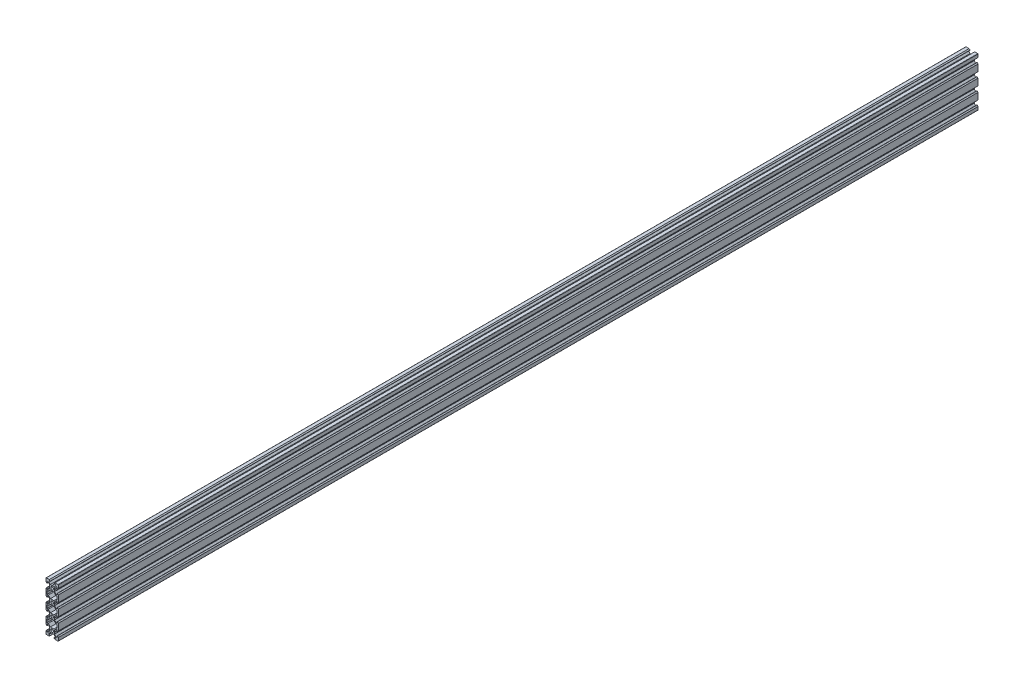
from build123d import *

# Parameters (mm, degrees)
SKETCH1_R           = 2.1
BOSS_EXTRUDE1_DEPTH = 1500


with BuildPart() as part:
    # Sketch1 → Boss-Extrude1 (new body)
    with BuildSketch(Plane.XY):
        with BuildLine():
            Line((4.58, -40), (9.5, -40))
            ThreePointArc((9.5, -40), (9.853553391, -39.853553391), (10, -39.5))
            Line((10, -39.5), (10, -34.58))
            Line((10, -34.58), (8.545, -33.125))
            Line((8.545, -33.125), (8.2, -33.125))
            Line((8.2, -33.125), (8.2, -35.5))
            Line((8.2, -35.5), (6.560660172, -35.5))
            Line((6.560660172, -35.5), (3.9, -32.839339828))
            Line((3.9, -32.839339828), (3.9, -30.21))
            Line((3.9, -30.21), (3.69, -30))
            Line((3.69, -30), (3.9, -29.79))
            Line((3.9, -29.79), (3.9, -27.160660172))
            Line((3.9, -27.160660172), (6.560660172, -24.5))
            Line((6.560660172, -24.5), (8.2, -24.5))
            Line((8.2, -24.5), (8.2, -26.875))
            Line((8.2, -26.875), (8.545, -26.875))
            Line((8.545, -26.875), (10, -25.42))
            Line((10, -25.42), (10, -14.58))
            Line((10, -14.58), (8.545, -13.125))
            Line((8.545, -13.125), (8.2, -13.125))
            Line((8.2, -13.125), (8.2, -15.5))
            Line((8.2, -15.5), (6.560660172, -15.5))
            Line((6.560660172, -15.5), (3.9, -12.839339828))
            Line((3.9, -12.839339828), (3.9, -10.21))
            Line((3.9, -10.21), (3.69, -10))
            Line((3.69, -10), (3.9, -9.79))
            Line((3.9, -9.79), (3.9, -7.160660172))
            Line((3.9, -7.160660172), (6.560660172, -4.5))
            Line((6.560660172, -4.5), (8.2, -4.5))
            Line((8.2, -4.5), (8.2, -6.875))
            Line((8.2, -6.875), (8.545, -6.875))
            Line((8.545, -6.875), (10, -5.42))
            Line((10, -5.42), (10, 5.42))
            Line((10, 5.42), (8.545, 6.875))
            Line((8.545, 6.875), (8.2, 6.875))
            Line((8.2, 6.875), (8.2, 4.5))
            Line((8.2, 4.5), (6.560660172, 4.5))
            Line((6.560660172, 4.5), (3.9, 7.160660172))
            Line((3.9, 7.160660172), (3.9, 9.79))
            Line((3.9, 9.79), (3.69, 10))
            Line((3.69, 10), (3.9, 10.21))
            Line((3.9, 10.21), (3.9, 12.839339828))
            Line((3.9, 12.839339828), (6.560660172, 15.5))
            Line((6.560660172, 15.5), (8.2, 15.5))
            Line((8.2, 15.5), (8.2, 13.125))
            Line((8.2, 13.125), (8.545, 13.125))
            Line((8.545, 13.125), (10, 14.58))
            Line((10, 14.58), (10, 25.42))
            Line((10, 25.42), (8.545, 26.875))
            Line((8.545, 26.875), (8.2, 26.875))
            Line((8.2, 26.875), (8.2, 24.5))
            Line((8.2, 24.5), (6.560660172, 24.5))
            Line((6.560660172, 24.5), (3.9, 27.160660172))
            Line((3.9, 27.160660172), (3.9, 29.79))
            Line((3.9, 29.79), (3.69, 30))
            Line((3.69, 30), (3.9, 30.21))
            Line((3.9, 30.21), (3.9, 32.839339828))
            Line((3.9, 32.839339828), (6.560660172, 35.5))
            Line((6.560660172, 35.5), (8.2, 35.5))
            Line((8.2, 35.5), (8.2, 33.125))
            Line((8.2, 33.125), (8.545, 33.125))
            Line((8.545, 33.125), (10, 34.58))
            Line((10, 34.58), (10, 39.5))
            ThreePointArc((10, 39.5), (9.853553391, 39.853553391), (9.5, 40))
            Line((9.5, 40), (4.58, 40))
            Line((4.58, 40), (3.125, 38.545))
            Line((3.125, 38.545), (3.125, 38.2))
            Line((3.125, 38.2), (5.5, 38.2))
            Line((5.5, 38.2), (5.5, 36.560660172))
            Line((5.5, 36.560660172), (2.839339828, 33.9))
            Line((2.839339828, 33.9), (0.21, 33.9))
            Line((0.21, 33.9), (0, 33.69))
            Line((0, 33.69), (-0.21, 33.9))
            Line((-0.21, 33.9), (-2.839339828, 33.9))
            Line((-2.839339828, 33.9), (-5.5, 36.560660172))
            Line((-5.5, 36.560660172), (-5.5, 38.2))
            Line((-5.5, 38.2), (-3.125, 38.2))
            Line((-3.125, 38.2), (-3.125, 38.545))
            Line((-3.125, 38.545), (-4.58, 40))
            Line((-4.58, 40), (-9.5, 40))
            ThreePointArc((-9.5, 40), (-9.853553391, 39.853553391), (-10, 39.5))
            Line((-10, 39.5), (-10, 34.58))
            Line((-10, 34.58), (-8.545, 33.125))
            Line((-8.545, 33.125), (-8.2, 33.125))
            Line((-8.2, 33.125), (-8.2, 35.5))
            Line((-8.2, 35.5), (-6.560660172, 35.5))
            Line((-6.560660172, 35.5), (-3.9, 32.839339828))
            Line((-3.9, 32.839339828), (-3.9, 30.21))
            Line((-3.9, 30.21), (-3.69, 30))
            Line((-3.69, 30), (-3.9, 29.79))
            Line((-3.9, 29.79), (-3.9, 27.160660172))
            Line((-3.9, 27.160660172), (-6.560660172, 24.5))
            Line((-6.560660172, 24.5), (-8.2, 24.5))
            Line((-8.2, 24.5), (-8.2, 26.875))
            Line((-8.2, 26.875), (-8.545, 26.875))
            Line((-8.545, 26.875), (-10, 25.42))
            Line((-10, 25.42), (-10, 14.58))
            Line((-10, 14.58), (-8.545, 13.125))
            Line((-8.545, 13.125), (-8.2, 13.125))
            Line((-8.2, 13.125), (-8.2, 15.5))
            Line((-8.2, 15.5), (-6.560660172, 15.5))
            Line((-6.560660172, 15.5), (-3.9, 12.839339828))
            Line((-3.9, 12.839339828), (-3.9, 10.21))
            Line((-3.9, 10.21), (-3.69, 10))
            Line((-3.69, 10), (-3.9, 9.79))
            Line((-3.9, 9.79), (-3.9, 7.160660172))
            Line((-3.9, 7.160660172), (-6.560660172, 4.5))
            Line((-6.560660172, 4.5), (-8.2, 4.5))
            Line((-8.2, 4.5), (-8.2, 6.875))
            Line((-8.2, 6.875), (-8.545, 6.875))
            Line((-8.545, 6.875), (-10, 5.42))
            Line((-10, 5.42), (-10, -5.42))
            Line((-10, -5.42), (-8.545, -6.875))
            Line((-8.545, -6.875), (-8.2, -6.875))
            Line((-8.2, -6.875), (-8.2, -4.5))
            Line((-8.2, -4.5), (-6.560660172, -4.5))
            Line((-6.560660172, -4.5), (-3.9, -7.160660172))
            Line((-3.9, -7.160660172), (-3.9, -9.79))
            Line((-3.9, -9.79), (-3.69, -10))
            Line((-3.69, -10), (-3.9, -10.21))
            Line((-3.9, -10.21), (-3.9, -12.839339828))
            Line((-3.9, -12.839339828), (-6.560660172, -15.5))
            Line((-6.560660172, -15.5), (-8.2, -15.5))
            Line((-8.2, -15.5), (-8.2, -13.125))
            Line((-8.2, -13.125), (-8.545, -13.125))
            Line((-8.545, -13.125), (-10, -14.58))
            Line((-10, -14.58), (-10, -25.42))
            Line((-10, -25.42), (-8.545, -26.875))
            Line((-8.545, -26.875), (-8.2, -26.875))
            Line((-8.2, -26.875), (-8.2, -24.5))
            Line((-8.2, -24.5), (-6.560660172, -24.5))
            Line((-6.560660172, -24.5), (-3.9, -27.160660172))
            Line((-3.9, -27.160660172), (-3.9, -29.79))
            Line((-3.9, -29.79), (-3.69, -30))
            Line((-3.69, -30), (-3.9, -30.21))
            Line((-3.9, -30.21), (-3.9, -32.839339828))
            Line((-3.9, -32.839339828), (-6.560660172, -35.5))
            Line((-6.560660172, -35.5), (-8.2, -35.5))
            Line((-8.2, -35.5), (-8.2, -33.125))
            Line((-8.2, -33.125), (-8.545, -33.125))
            Line((-8.545, -33.125), (-10, -34.58))
            Line((-10, -34.58), (-10, -39.5))
            ThreePointArc((-10, -39.5), (-9.853553391, -39.853553391), (-9.5, -40))
            Line((-9.5, -40), (-4.58, -40))
            Line((-4.58, -40), (-3.125, -38.545))
            Line((-3.125, -38.545), (-3.125, -38.2))
            Line((-3.125, -38.2), (-5.5, -38.2))
            Line((-5.5, -38.2), (-5.5, -36.560660172))
            Line((-5.5, -36.560660172), (-2.839339828, -33.9))
            Line((-2.839339828, -33.9), (-0.21, -33.9))
            Line((-0.21, -33.9), (0, -33.69))
            Line((0, -33.69), (0.21, -33.9))
            Line((0.21, -33.9), (2.839339828, -33.9))
            Line((2.839339828, -33.9), (5.5, -36.560660172))
            Line((5.5, -36.560660172), (5.5, -38.2))
            Line((5.5, -38.2), (3.125, -38.2))
            Line((3.125, -38.2), (3.125, -38.545))
            Line((3.125, -38.545), (4.58, -40))
        make_face()
        with Locations((0, -30)):
            Circle(SKETCH1_R, mode=Mode.SUBTRACT)
        Polygon((-6.239339828, -22.7), (-8.2, -22.7), (-8.2, -17.3), (-6.239339828, -17.3), (-2.839339828, -13.9), (2.839339828, -13.9), (6.239339828, -17.3), (8.2, -17.3), (8.2, -22.7), (6.239339828, -22.7), (2.839339828, -26.1), (-2.839339828, -26.1), align=None, mode=Mode.SUBTRACT)
        with Locations((0, -10)):
            Circle(SKETCH1_R, mode=Mode.SUBTRACT)
        Polygon((-6.239339828, -2.7), (-8.2, -2.7), (-8.2, 2.7), (-6.239339828, 2.7), (-2.839339828, 6.1), (2.839339828, 6.1), (6.239339828, 2.7), (8.2, 2.7), (8.2, -2.7), (6.239339828, -2.7), (2.839339828, -6.1), (-2.839339828, -6.1), align=None, mode=Mode.SUBTRACT)
        with Locations((0, 10)):
            Circle(SKETCH1_R, mode=Mode.SUBTRACT)
        Polygon((-6.239339828, 17.3), (-8.2, 17.3), (-8.2, 22.7), (-6.239339828, 22.7), (-2.839339828, 26.1), (2.839339828, 26.1), (6.239339828, 22.7), (8.2, 22.7), (8.2, 17.3), (6.239339828, 17.3), (2.839339828, 13.9), (-2.839339828, 13.9), align=None, mode=Mode.SUBTRACT)
        with Locations((0, 30)):
            Circle(SKETCH1_R, mode=Mode.SUBTRACT)
    extrude(amount=BOSS_EXTRUDE1_DEPTH)


solid = part.part
